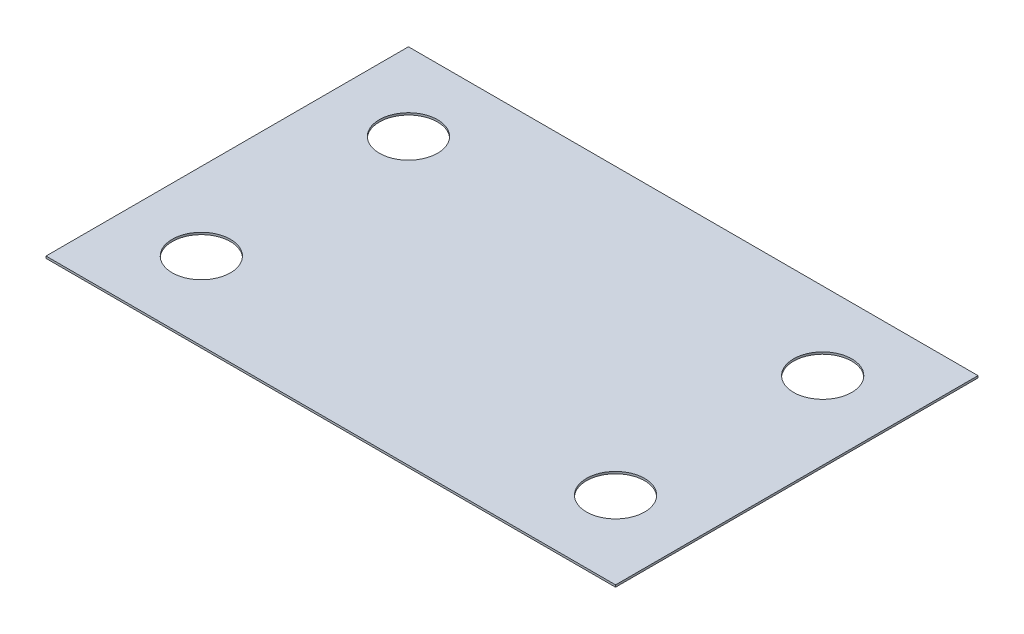
from build123d import *

# Parameters (mm, degrees)
SKETCH1_W           = 69.85
SKETCH1_H           = 44.45
SKETCH1_R           = 3.5687
BOSS_EXTRUDE1_DEPTH = 0.254


with BuildPart() as part:
    # Sketch1 → Boss-Extrude1 (new body)
    with BuildSketch(Plane(origin=(0, 0, 0), x_dir=(1, 0, 0), z_dir=(0, 1, 0))):
        with Locations((34.925, 22.225)):
            Rectangle(SKETCH1_W, SKETCH1_H)
        with Locations((9.525, 9.525)):
            Circle(SKETCH1_R, mode=Mode.SUBTRACT)
        with Locations((9.525, 34.925)):
            Circle(SKETCH1_R, mode=Mode.SUBTRACT)
        with Locations((60.325, 9.525)):
            Circle(SKETCH1_R, mode=Mode.SUBTRACT)
        with Locations((60.325, 34.925)):
            Circle(SKETCH1_R, mode=Mode.SUBTRACT)
    extrude(amount=BOSS_EXTRUDE1_DEPTH)


solid = part.part
